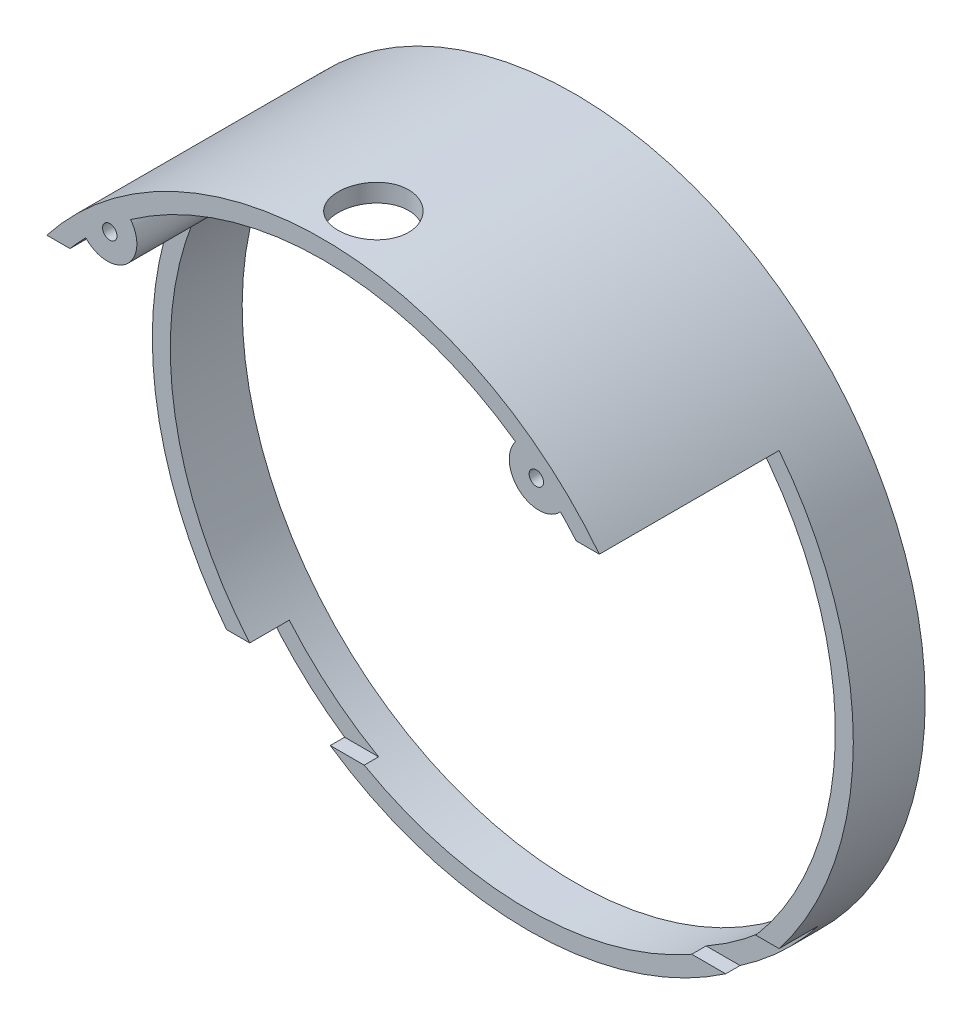
from build123d import *

# Parameters (mm, degrees)
SKETCH2_R               = 97.5
SKETCH2_R_2             = 92.5
BOSS_EXTRUDE1_DEPTH     = 70
SKETCH3_W               = 110
SKETCH3_H               = 114
CUT_EXTRUDE1_DEPTH      = 98.5
SKETCH4_W               = 100
SKETCH4_H               = 120
CUT_EXTRUDE2_DEPTH      = 98.5
CUT_EXTRUDE2_DEPTH_BACK = 98.5
SKETCH5_W               = 61
SKETCH5_H               = 20.506210941
CUT_EXTRUDE3_DEPTH      = 98.5
CUT_EXTRUDE3_DEPTH_BACK = 98.5
SKETCH6_R               = 9.784293737
CUT_EXTRUDE4_DEPTH      = 98.5
BOSS_EXTRUDE2_DEPTH     = 70
SKETCH9_R               = 2
CUT_EXTRUDE5_DEPTH      = 71.0000001


with BuildPart() as part:
    # Sketch2 → Boss-Extrude1 (new body)
    with BuildSketch(Plane.XY):
        Circle(SKETCH2_R)
        Circle(SKETCH2_R_2, mode=Mode.SUBTRACT)
    extrude(amount=BOSS_EXTRUDE1_DEPTH)

    # Sketch3 → Cut-Extrude1 (cut, through all)
    with BuildSketch(Plane(origin=(0, 0, 0), x_dir=(1, 0, 0), z_dir=(0, 1, 0))):
        with Locations((0, -70)):
            Rectangle(SKETCH3_W, SKETCH3_H)
    extrude(amount=-CUT_EXTRUDE1_DEPTH, mode=Mode.SUBTRACT)

    # Sketch4 → Cut-Extrude2 (cut, two sides)
    with BuildSketch(Plane(origin=(0, 0, 0), x_dir=(0, 0, -1), z_dir=(1, 0, 0))) as cut_extrude2_sk:
        with Locations((-70, 0)):
            Rectangle(SKETCH4_W, SKETCH4_H)
    extrude(amount=CUT_EXTRUDE2_DEPTH, mode=Mode.SUBTRACT)
    extrude(cut_extrude2_sk.sketch, amount=-CUT_EXTRUDE2_DEPTH_BACK, mode=Mode.SUBTRACT)

    # Sketch5 → Cut-Extrude3 (cut, two sides)
    with BuildSketch(Plane(origin=(0, 0, 0), x_dir=(0, 0, -1), z_dir=(1, 0, 0))) as cut_extrude3_sk:
        with Locations((-39.5, -70.253105471)):
            Rectangle(SKETCH5_W, SKETCH5_H)
    extrude(amount=CUT_EXTRUDE3_DEPTH, mode=Mode.SUBTRACT)
    extrude(cut_extrude3_sk.sketch, amount=-CUT_EXTRUDE3_DEPTH_BACK, mode=Mode.SUBTRACT)

    # Sketch6 → Cut-Extrude4 (cut, through all)
    with BuildSketch(Plane(origin=(0, 0, 0), x_dir=(1, 0, 0), z_dir=(0, 1, 0))):
        with Locations((0, -56.012862066)):
            Circle(SKETCH6_R)
    extrude(amount=CUT_EXTRUDE4_DEPTH, mode=Mode.SUBTRACT)

    # Sketch8 → Boss-Extrude2 (add)
    with BuildSketch(Plane.XY):
        with BuildLine():
            ThreePointArc((66.0209996, 64.787943414), (54.682390857, 64.138601978), (53.530180965, 75.437190602))
            ThreePointArc((53.530180965, 75.437190602), (60.012272162, 70.390178221), (66.0209996, 64.787943414))
        make_face()
    boss_extrude2 = extrude(amount=BOSS_EXTRUDE2_DEPTH)

    # Sketch9 → Cut-Extrude5 (cut, through all)
    with BuildSketch(Plane(origin=(0, 0, 0), x_dir=(-1, 0, 0), z_dir=(0, 0, -1))):
        with Locations((-59.32689754, 69.571871503)):
            Circle(SKETCH9_R)
    cut_extrude5 = extrude(amount=-CUT_EXTRUDE5_DEPTH, mode=Mode.SUBTRACT)

    # Mirror1: Boss-Extrude2, Cut-Extrude5 across plane
    add(boss_extrude2.mirror(Plane(origin=(0, 0, 0), x_dir=(0, 0, 1), z_dir=(1, 0, 0))))
    add(cut_extrude5.mirror(Plane(origin=(0, 0, 0), x_dir=(0, 0, 1), z_dir=(1, 0, 0))), mode=Mode.SUBTRACT)


solid = part.part
